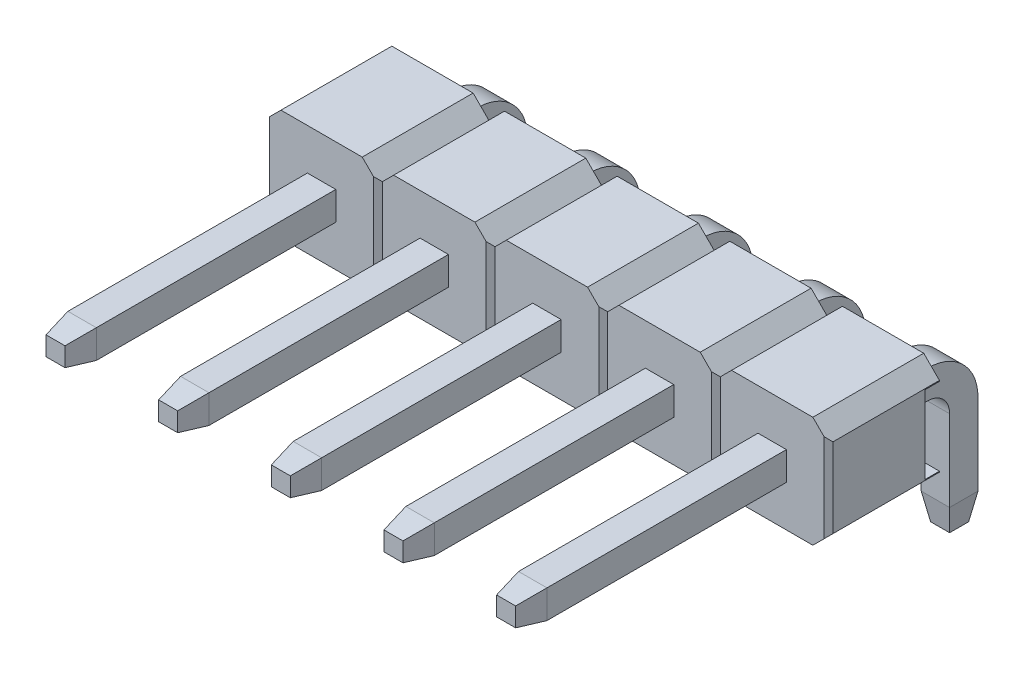
from build123d import *
from OCP.BRepFilletAPI import BRepFilletAPI_MakeChamfer

# Parameters (mm, degrees)
EXTRUDE1_DEPTH          = 1.25
CUT_EXTRUDE3_DEPTH      = 3.176671771
LPATTERN4_COUNT         = 3
LPATTERN4_PITCH         = 2.54
LPATTERN4_COUNT_DIR2    = 3
LPATTERN4_PITCH_DIR2    = 2.54
CUT_EXTRUDE1_DEPTH      = 7.591471763
CUT_EXTRUDE1_DEPTH_BACK = 7.591471763
SKETCH2_W               = 1.752893218
SKETCH2_H               = 0.33
EXTRUDE_THIN1_DEPTH     = 0.32
LPATTERN5_COUNT         = 3
LPATTERN5_PITCH         = 2.54
LPATTERN5_COUNT_DIR2    = 3
LPATTERN5_PITCH_DIR2    = 2.54
CHAMFER2_SIZE           = 0.6
CHAMFER2_SIZE2          = 0.105796188
FILLET1_R               = 0.5
FILLET2_R               = 1.14


with BuildPart() as part:
    # Sketch1 → Extrude1 (new, symmetric)
    with BuildSketch(Plane.XY):
        Polygon((-1.27, 0.896446609), (-0.916446609, 1.25), (0.916446609, 1.25), (1.27, 0.896446609), (1.27, -0.896446609), (0.916446609, -1.25), (-0.916446609, -1.25), (-1.27, -0.896446609), align=None)
    extrude1 = extrude(amount=EXTRUDE1_DEPTH, both=True)

    # Sketch4 → Cut-Extrude3 (cut, symmetric)
    with BuildSketch(Plane(origin=(0, 0, 0), x_dir=(1, 0, 0), z_dir=(0, 1, 0))):
        Polygon((-1.27, -1.15), (-1.17, -1.25), (-1.27, -1.25), align=None)
        Polygon((1.17, -1.25), (1.27, -1.15), (1.27, -1.25), align=None)
    cut_extrude3 = extrude(amount=CUT_EXTRUDE3_DEPTH, both=True, mode=Mode.SUBTRACT)

    # LPattern4: Extrude1, Cut-Extrude3 3 × 3
    with Locations(*[Vector(-1, 0, 0) * (i * LPATTERN4_PITCH) + Vector(1, 0, 0) * (j * LPATTERN4_PITCH_DIR2) for i in range(LPATTERN4_COUNT) for j in range(LPATTERN4_COUNT_DIR2) if (i, j) != (0, 0)]):
        add(extrude1)
        add(cut_extrude3, mode=Mode.SUBTRACT)

    # Sketch2 → Cut-Extrude1 (cut, two sides: drawn at the far end of the back side and taken through both)
    with BuildSketch(Plane(origin=(0, 0, 0), x_dir=(0, -1, 0), z_dir=(1, 0, 0)).offset(-CUT_EXTRUDE1_DEPTH_BACK)):
        with Locations((0, 1.085)):
            Rectangle(SKETCH2_W, SKETCH2_H)
    extrude(amount=CUT_EXTRUDE1_DEPTH + CUT_EXTRUDE1_DEPTH_BACK, mode=Mode.SUBTRACT)

    # Sketch3 → Extrude-Thin1 (add, symmetric)
    with BuildSketch(Plane(origin=(0, 0, 0), x_dir=(0, 0, -1), z_dir=(1, 0, 0))):
        Polygon((-7.25, -0.32), (2.43, -0.32), (2.43, -3.25), (3.07, -3.25), (3.07, 0.32), (-7.25, 0.32), align=None)
    extrude_thin1 = extrude(amount=EXTRUDE_THIN1_DEPTH, both=True)

    # LPattern5: Extrude-Thin1 3 × 3
    with Locations(*[Vector(1, 0, 0) * (i * LPATTERN5_PITCH) + Vector(-1, 0, 0) * (j * LPATTERN5_PITCH_DIR2) for i in range(LPATTERN5_COUNT) for j in range(LPATTERN5_COUNT_DIR2) if (i, j) != (0, 0)]):
        add(extrude_thin1)

    # Chamfer2: one chamfer whose edges measure the first distance from different faces: ONE call of the kernel's chamfer builder (chamfer() names one face for all edges)
    chamfer2_edges_1 = [part.edges().sort_by_distance(p)[0] for p in [
        (0.32, 0, 7.25),
    ]]
    chamfer2_side_1 = [part.faces().sort_by_distance(p)[0] for p in [
        (0.32, 0, 4.25),
    ]]
    chamfer2_edges_2 = [part.edges().sort_by_distance(p)[0] for p in [
        (0, -0.32, 7.25),
    ]]
    chamfer2_side_2 = [part.faces().sort_by_distance(p)[0] for p in [
        (0, -0.32, 4.25),
    ]]
    chamfer2_edges_3 = [part.edges().sort_by_distance(p)[0] for p in [
        (-0.32, 0, 7.25),
    ]]
    chamfer2_side_3 = [part.faces().sort_by_distance(p)[0] for p in [
        (-0.32, 0, 4.25),
    ]]
    chamfer2_edges_4 = [part.edges().sort_by_distance(p)[0] for p in [
        (0, 0.32, 7.25),
    ]]
    chamfer2_side_4 = [part.faces().sort_by_distance(p)[0] for p in [
        (0, 0.32, 4.25),
    ]]
    chamfer2_edges_5 = [part.edges().sort_by_distance(p)[0] for p in [
        (0.32, -3.25, -2.75),
    ]]
    chamfer2_side_5 = [part.faces().sort_by_distance(p)[0] for p in [
        (0.32, -1.029537402, -2.430462598),
    ]]
    chamfer2_edges_6 = [part.edges().sort_by_distance(p)[0] for p in [
        (0, -3.25, -3.07),
    ]]
    chamfer2_side_6 = [part.faces().sort_by_distance(p)[0] for p in [
        (0, -1.465, -3.07),
    ]]
    chamfer2_edges_7 = [part.edges().sort_by_distance(p)[0] for p in [
        (-0.32, -3.25, -2.75),
    ]]
    chamfer2_side_7 = [part.faces().sort_by_distance(p)[0] for p in [
        (-0.32, -1.029537402, -2.430462598),
    ]]
    chamfer2_edges_8 = [part.edges().sort_by_distance(p)[0] for p in [
        (0, -3.25, -2.43),
    ]]
    chamfer2_side_8 = [part.faces().sort_by_distance(p)[0] for p in [
        (0, -1.785, -2.43),
    ]]
    chamfer2_edges_9 = [part.edges().sort_by_distance(p)[0] for p in [
        (5.4, -3.25, -2.75),
    ]]
    chamfer2_side_9 = [part.faces().sort_by_distance(p)[0] for p in [
        (5.4, -1.029537402, -2.430462598),
    ]]
    chamfer2_edges_10 = [part.edges().sort_by_distance(p)[0] for p in [
        (5.08, -3.25, -3.07),
    ]]
    chamfer2_side_10 = [part.faces().sort_by_distance(p)[0] for p in [
        (5.08, -1.465, -3.07),
    ]]
    chamfer2_edges_11 = [part.edges().sort_by_distance(p)[0] for p in [
        (4.76, -3.25, -2.75),
    ]]
    chamfer2_side_11 = [part.faces().sort_by_distance(p)[0] for p in [
        (4.76, -1.029537402, -2.430462598),
    ]]
    chamfer2_edges_12 = [part.edges().sort_by_distance(p)[0] for p in [
        (5.08, -3.25, -2.43),
    ]]
    chamfer2_side_12 = [part.faces().sort_by_distance(p)[0] for p in [
        (5.08, -1.785, -2.43),
    ]]
    chamfer2_edges_13 = [part.edges().sort_by_distance(p)[0] for p in [
        (2.86, -3.25, -2.75),
    ]]
    chamfer2_side_13 = [part.faces().sort_by_distance(p)[0] for p in [
        (2.86, -1.029537402, -2.430462598),
    ]]
    chamfer2_edges_14 = [part.edges().sort_by_distance(p)[0] for p in [
        (2.54, -3.25, -3.07),
    ]]
    chamfer2_side_14 = [part.faces().sort_by_distance(p)[0] for p in [
        (2.54, -1.465, -3.07),
    ]]
    chamfer2_edges_15 = [part.edges().sort_by_distance(p)[0] for p in [
        (2.22, -3.25, -2.75),
    ]]
    chamfer2_side_15 = [part.faces().sort_by_distance(p)[0] for p in [
        (2.22, -1.029537402, -2.430462598),
    ]]
    chamfer2_edges_16 = [part.edges().sort_by_distance(p)[0] for p in [
        (2.54, -3.25, -2.43),
    ]]
    chamfer2_side_16 = [part.faces().sort_by_distance(p)[0] for p in [
        (2.54, -1.785, -2.43),
    ]]
    chamfer2_edges_17 = [part.edges().sort_by_distance(p)[0] for p in [
        (-4.76, -3.25, -2.75),
    ]]
    chamfer2_side_17 = [part.faces().sort_by_distance(p)[0] for p in [
        (-4.76, -1.029537402, -2.430462598),
    ]]
    chamfer2_edges_18 = [part.edges().sort_by_distance(p)[0] for p in [
        (-5.08, -3.25, -3.07),
    ]]
    chamfer2_side_18 = [part.faces().sort_by_distance(p)[0] for p in [
        (-5.08, -1.465, -3.07),
    ]]
    chamfer2_edges_19 = [part.edges().sort_by_distance(p)[0] for p in [
        (-5.4, -3.25, -2.75),
    ]]
    chamfer2_side_19 = [part.faces().sort_by_distance(p)[0] for p in [
        (-5.4, -1.029537402, -2.430462598),
    ]]
    chamfer2_edges_20 = [part.edges().sort_by_distance(p)[0] for p in [
        (-5.08, -3.25, -2.43),
    ]]
    chamfer2_side_20 = [part.faces().sort_by_distance(p)[0] for p in [
        (-5.08, -1.785, -2.43),
    ]]
    chamfer2_edges_21 = [part.edges().sort_by_distance(p)[0] for p in [
        (-2.22, -3.25, -2.75),
    ]]
    chamfer2_side_21 = [part.faces().sort_by_distance(p)[0] for p in [
        (-2.22, -1.029537402, -2.430462598),
    ]]
    chamfer2_edges_22 = [part.edges().sort_by_distance(p)[0] for p in [
        (-2.54, -3.25, -3.07),
    ]]
    chamfer2_side_22 = [part.faces().sort_by_distance(p)[0] for p in [
        (-2.54, -1.465, -3.07),
    ]]
    chamfer2_edges_23 = [part.edges().sort_by_distance(p)[0] for p in [
        (-2.86, -3.25, -2.75),
    ]]
    chamfer2_side_23 = [part.faces().sort_by_distance(p)[0] for p in [
        (-2.86, -1.029537402, -2.430462598),
    ]]
    chamfer2_edges_24 = [part.edges().sort_by_distance(p)[0] for p in [
        (-2.54, -3.25, -2.43),
    ]]
    chamfer2_side_24 = [part.faces().sort_by_distance(p)[0] for p in [
        (-2.54, -1.785, -2.43),
    ]]
    chamfer2_edges_25 = [part.edges().sort_by_distance(p)[0] for p in [
        (5.4, 0, 7.25),
    ]]
    chamfer2_side_25 = [part.faces().sort_by_distance(p)[0] for p in [
        (5.4, 0, 4.25),
    ]]
    chamfer2_edges_26 = [part.edges().sort_by_distance(p)[0] for p in [
        (5.08, -0.32, 7.25),
    ]]
    chamfer2_side_26 = [part.faces().sort_by_distance(p)[0] for p in [
        (5.08, -0.32, 4.25),
    ]]
    chamfer2_edges_27 = [part.edges().sort_by_distance(p)[0] for p in [
        (4.76, 0, 7.25),
    ]]
    chamfer2_side_27 = [part.faces().sort_by_distance(p)[0] for p in [
        (4.76, 0, 4.25),
    ]]
    chamfer2_edges_28 = [part.edges().sort_by_distance(p)[0] for p in [
        (5.08, 0.32, 7.25),
    ]]
    chamfer2_side_28 = [part.faces().sort_by_distance(p)[0] for p in [
        (5.08, 0.32, 4.25),
    ]]
    chamfer2_edges_29 = [part.edges().sort_by_distance(p)[0] for p in [
        (2.86, 0, 7.25),
    ]]
    chamfer2_side_29 = [part.faces().sort_by_distance(p)[0] for p in [
        (2.86, 0, 4.25),
    ]]
    chamfer2_edges_30 = [part.edges().sort_by_distance(p)[0] for p in [
        (2.54, -0.32, 7.25),
    ]]
    chamfer2_side_30 = [part.faces().sort_by_distance(p)[0] for p in [
        (2.54, -0.32, 4.25),
    ]]
    chamfer2_edges_31 = [part.edges().sort_by_distance(p)[0] for p in [
        (2.22, 0, 7.25),
    ]]
    chamfer2_side_31 = [part.faces().sort_by_distance(p)[0] for p in [
        (2.22, 0, 4.25),
    ]]
    chamfer2_edges_32 = [part.edges().sort_by_distance(p)[0] for p in [
        (2.54, 0.32, 7.25),
    ]]
    chamfer2_side_32 = [part.faces().sort_by_distance(p)[0] for p in [
        (2.54, 0.32, 4.25),
    ]]
    chamfer2_edges_33 = [part.edges().sort_by_distance(p)[0] for p in [
        (-2.22, 0, 7.25),
    ]]
    chamfer2_side_33 = [part.faces().sort_by_distance(p)[0] for p in [
        (-2.22, 0, 4.25),
    ]]
    chamfer2_edges_34 = [part.edges().sort_by_distance(p)[0] for p in [
        (-2.54, -0.32, 7.25),
    ]]
    chamfer2_side_34 = [part.faces().sort_by_distance(p)[0] for p in [
        (-2.54, -0.32, 4.25),
    ]]
    chamfer2_edges_35 = [part.edges().sort_by_distance(p)[0] for p in [
        (-2.86, 0, 7.25),
    ]]
    chamfer2_side_35 = [part.faces().sort_by_distance(p)[0] for p in [
        (-2.86, 0, 4.25),
    ]]
    chamfer2_edges_36 = [part.edges().sort_by_distance(p)[0] for p in [
        (-2.54, 0.32, 7.25),
    ]]
    chamfer2_side_36 = [part.faces().sort_by_distance(p)[0] for p in [
        (-2.54, 0.32, 4.25),
    ]]
    chamfer2_edges_37 = [part.edges().sort_by_distance(p)[0] for p in [
        (-4.76, 0, 7.25),
    ]]
    chamfer2_side_37 = [part.faces().sort_by_distance(p)[0] for p in [
        (-4.76, 0, 4.25),
    ]]
    chamfer2_edges_38 = [part.edges().sort_by_distance(p)[0] for p in [
        (-5.08, -0.32, 7.25),
    ]]
    chamfer2_side_38 = [part.faces().sort_by_distance(p)[0] for p in [
        (-5.08, -0.32, 4.25),
    ]]
    chamfer2_edges_39 = [part.edges().sort_by_distance(p)[0] for p in [
        (-5.4, 0, 7.25),
    ]]
    chamfer2_side_39 = [part.faces().sort_by_distance(p)[0] for p in [
        (-5.4, 0, 4.25),
    ]]
    chamfer2_edges_40 = [part.edges().sort_by_distance(p)[0] for p in [
        (-5.08, 0.32, 7.25),
    ]]
    chamfer2_side_40 = [part.faces().sort_by_distance(p)[0] for p in [
        (-5.08, 0.32, 4.25),
    ]]
    chamfer2 = BRepFilletAPI_MakeChamfer(part.part.solid().wrapped)
    for e in chamfer2_edges_1:
        chamfer2.Add(CHAMFER2_SIZE, CHAMFER2_SIZE2, e.wrapped, chamfer2_side_1[0].wrapped)  # the first distance lies on this face
    for e in chamfer2_edges_2:
        chamfer2.Add(CHAMFER2_SIZE, CHAMFER2_SIZE2, e.wrapped, chamfer2_side_2[0].wrapped)  # the first distance lies on this face
    for e in chamfer2_edges_3:
        chamfer2.Add(CHAMFER2_SIZE, CHAMFER2_SIZE2, e.wrapped, chamfer2_side_3[0].wrapped)  # the first distance lies on this face
    for e in chamfer2_edges_4:
        chamfer2.Add(CHAMFER2_SIZE, CHAMFER2_SIZE2, e.wrapped, chamfer2_side_4[0].wrapped)  # the first distance lies on this face
    for e in chamfer2_edges_5:
        chamfer2.Add(CHAMFER2_SIZE, CHAMFER2_SIZE2, e.wrapped, chamfer2_side_5[0].wrapped)  # the first distance lies on this face
    for e in chamfer2_edges_6:
        chamfer2.Add(CHAMFER2_SIZE, CHAMFER2_SIZE2, e.wrapped, chamfer2_side_6[0].wrapped)  # the first distance lies on this face
    for e in chamfer2_edges_7:
        chamfer2.Add(CHAMFER2_SIZE, CHAMFER2_SIZE2, e.wrapped, chamfer2_side_7[0].wrapped)  # the first distance lies on this face
    for e in chamfer2_edges_8:
        chamfer2.Add(CHAMFER2_SIZE, CHAMFER2_SIZE2, e.wrapped, chamfer2_side_8[0].wrapped)  # the first distance lies on this face
    for e in chamfer2_edges_9:
        chamfer2.Add(CHAMFER2_SIZE, CHAMFER2_SIZE2, e.wrapped, chamfer2_side_9[0].wrapped)  # the first distance lies on this face
    for e in chamfer2_edges_10:
        chamfer2.Add(CHAMFER2_SIZE, CHAMFER2_SIZE2, e.wrapped, chamfer2_side_10[0].wrapped)  # the first distance lies on this face
    for e in chamfer2_edges_11:
        chamfer2.Add(CHAMFER2_SIZE, CHAMFER2_SIZE2, e.wrapped, chamfer2_side_11[0].wrapped)  # the first distance lies on this face
    for e in chamfer2_edges_12:
        chamfer2.Add(CHAMFER2_SIZE, CHAMFER2_SIZE2, e.wrapped, chamfer2_side_12[0].wrapped)  # the first distance lies on this face
    for e in chamfer2_edges_13:
        chamfer2.Add(CHAMFER2_SIZE, CHAMFER2_SIZE2, e.wrapped, chamfer2_side_13[0].wrapped)  # the first distance lies on this face
    for e in chamfer2_edges_14:
        chamfer2.Add(CHAMFER2_SIZE, CHAMFER2_SIZE2, e.wrapped, chamfer2_side_14[0].wrapped)  # the first distance lies on this face
    for e in chamfer2_edges_15:
        chamfer2.Add(CHAMFER2_SIZE, CHAMFER2_SIZE2, e.wrapped, chamfer2_side_15[0].wrapped)  # the first distance lies on this face
    for e in chamfer2_edges_16:
        chamfer2.Add(CHAMFER2_SIZE, CHAMFER2_SIZE2, e.wrapped, chamfer2_side_16[0].wrapped)  # the first distance lies on this face
    for e in chamfer2_edges_17:
        chamfer2.Add(CHAMFER2_SIZE, CHAMFER2_SIZE2, e.wrapped, chamfer2_side_17[0].wrapped)  # the first distance lies on this face
    for e in chamfer2_edges_18:
        chamfer2.Add(CHAMFER2_SIZE, CHAMFER2_SIZE2, e.wrapped, chamfer2_side_18[0].wrapped)  # the first distance lies on this face
    for e in chamfer2_edges_19:
        chamfer2.Add(CHAMFER2_SIZE, CHAMFER2_SIZE2, e.wrapped, chamfer2_side_19[0].wrapped)  # the first distance lies on this face
    for e in chamfer2_edges_20:
        chamfer2.Add(CHAMFER2_SIZE, CHAMFER2_SIZE2, e.wrapped, chamfer2_side_20[0].wrapped)  # the first distance lies on this face
    for e in chamfer2_edges_21:
        chamfer2.Add(CHAMFER2_SIZE, CHAMFER2_SIZE2, e.wrapped, chamfer2_side_21[0].wrapped)  # the first distance lies on this face
    for e in chamfer2_edges_22:
        chamfer2.Add(CHAMFER2_SIZE, CHAMFER2_SIZE2, e.wrapped, chamfer2_side_22[0].wrapped)  # the first distance lies on this face
    for e in chamfer2_edges_23:
        chamfer2.Add(CHAMFER2_SIZE, CHAMFER2_SIZE2, e.wrapped, chamfer2_side_23[0].wrapped)  # the first distance lies on this face
    for e in chamfer2_edges_24:
        chamfer2.Add(CHAMFER2_SIZE, CHAMFER2_SIZE2, e.wrapped, chamfer2_side_24[0].wrapped)  # the first distance lies on this face
    for e in chamfer2_edges_25:
        chamfer2.Add(CHAMFER2_SIZE, CHAMFER2_SIZE2, e.wrapped, chamfer2_side_25[0].wrapped)  # the first distance lies on this face
    for e in chamfer2_edges_26:
        chamfer2.Add(CHAMFER2_SIZE, CHAMFER2_SIZE2, e.wrapped, chamfer2_side_26[0].wrapped)  # the first distance lies on this face
    for e in chamfer2_edges_27:
        chamfer2.Add(CHAMFER2_SIZE, CHAMFER2_SIZE2, e.wrapped, chamfer2_side_27[0].wrapped)  # the first distance lies on this face
    for e in chamfer2_edges_28:
        chamfer2.Add(CHAMFER2_SIZE, CHAMFER2_SIZE2, e.wrapped, chamfer2_side_28[0].wrapped)  # the first distance lies on this face
    for e in chamfer2_edges_29:
        chamfer2.Add(CHAMFER2_SIZE, CHAMFER2_SIZE2, e.wrapped, chamfer2_side_29[0].wrapped)  # the first distance lies on this face
    for e in chamfer2_edges_30:
        chamfer2.Add(CHAMFER2_SIZE, CHAMFER2_SIZE2, e.wrapped, chamfer2_side_30[0].wrapped)  # the first distance lies on this face
    for e in chamfer2_edges_31:
        chamfer2.Add(CHAMFER2_SIZE, CHAMFER2_SIZE2, e.wrapped, chamfer2_side_31[0].wrapped)  # the first distance lies on this face
    for e in chamfer2_edges_32:
        chamfer2.Add(CHAMFER2_SIZE, CHAMFER2_SIZE2, e.wrapped, chamfer2_side_32[0].wrapped)  # the first distance lies on this face
    for e in chamfer2_edges_33:
        chamfer2.Add(CHAMFER2_SIZE, CHAMFER2_SIZE2, e.wrapped, chamfer2_side_33[0].wrapped)  # the first distance lies on this face
    for e in chamfer2_edges_34:
        chamfer2.Add(CHAMFER2_SIZE, CHAMFER2_SIZE2, e.wrapped, chamfer2_side_34[0].wrapped)  # the first distance lies on this face
    for e in chamfer2_edges_35:
        chamfer2.Add(CHAMFER2_SIZE, CHAMFER2_SIZE2, e.wrapped, chamfer2_side_35[0].wrapped)  # the first distance lies on this face
    for e in chamfer2_edges_36:
        chamfer2.Add(CHAMFER2_SIZE, CHAMFER2_SIZE2, e.wrapped, chamfer2_side_36[0].wrapped)  # the first distance lies on this face
    for e in chamfer2_edges_37:
        chamfer2.Add(CHAMFER2_SIZE, CHAMFER2_SIZE2, e.wrapped, chamfer2_side_37[0].wrapped)  # the first distance lies on this face
    for e in chamfer2_edges_38:
        chamfer2.Add(CHAMFER2_SIZE, CHAMFER2_SIZE2, e.wrapped, chamfer2_side_38[0].wrapped)  # the first distance lies on this face
    for e in chamfer2_edges_39:
        chamfer2.Add(CHAMFER2_SIZE, CHAMFER2_SIZE2, e.wrapped, chamfer2_side_39[0].wrapped)  # the first distance lies on this face
    for e in chamfer2_edges_40:
        chamfer2.Add(CHAMFER2_SIZE, CHAMFER2_SIZE2, e.wrapped, chamfer2_side_40[0].wrapped)  # the first distance lies on this face
    add(Compound.cast(chamfer2.Shape()), mode=Mode.REPLACE)

    # Fillet1
    fillet1_edges = [part.edges().sort_by_distance(p)[0] for p in [
        (0, -0.32, -2.43),
        (-5.08, -0.32, -2.43),
        (-2.54, -0.32, -2.43),
        (5.08, -0.32, -2.43),
        (2.54, -0.32, -2.43),
    ]]
    fillet(fillet1_edges, radius=FILLET1_R)

    # Fillet2
    fillet2_edges = [part.edges().sort_by_distance(p)[0] for p in [
        (0, 0.32, -3.07),
        (-5.08, 0.32, -3.07),
        (-2.54, 0.32, -3.07),
        (2.54, 0.32, -3.07),
        (5.08, 0.32, -3.07),
    ]]
    fillet(fillet2_edges, radius=FILLET2_R)


solid = part.part
